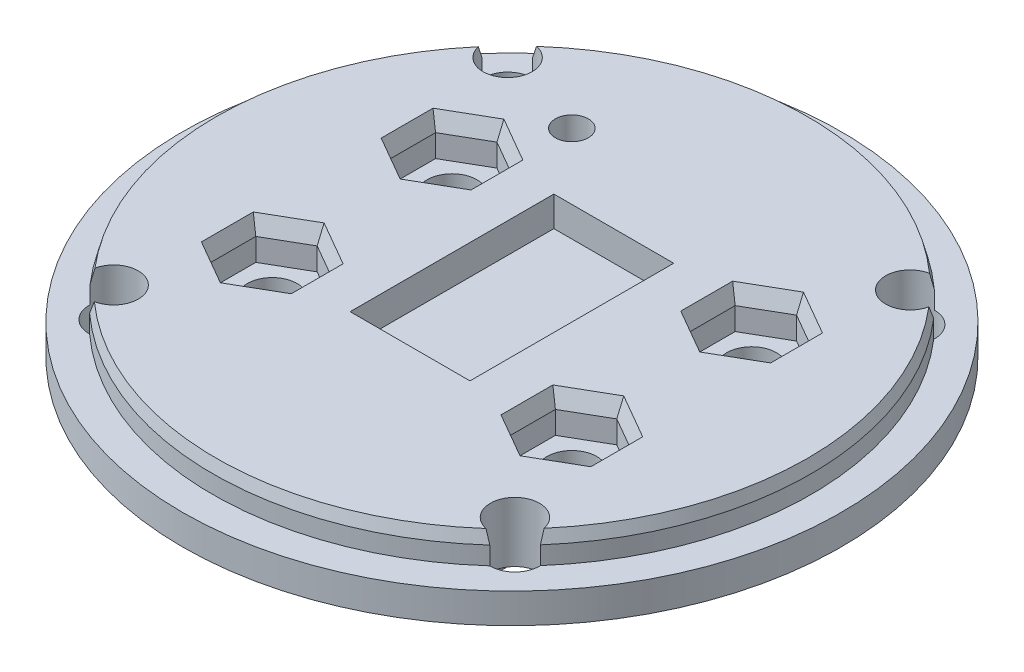
from build123d import *

# Parameters (mm, degrees)
SKETCH_1_R            = 55
EXTRUDE_1_DEPTH       = 5
SKETCH_2_R            = 49.9
EXTRUDE_2_DEPTH       = 5
SKETCH_3_W            = 35
SKETCH_3_H            = 45
EXTRUDE_3_DEPTH       = 25
SKETCH_4_W            = 20.2
SKETCH_4_H            = 10.3
CUT_EXTRUDE_1_DEPTH   = 78.5
SKETCH_5_R            = 4.1
CUT_EXTRUDE_2_DEPTH   = 11
SKETCH_6_R            = 2.75
CUT_EXTRUDE_3_DEPTH   = 36
CHAMFER1_SIZE         = 2
CHAMFER1_SIZE2        = 0.535898385
CHAMFER1_PART_2_SIZE  = 2
CHAMFER1_PART_2_SIZE2 = 0.535898385
CHAMFER1_PART_3_SIZE  = 2
CHAMFER1_PART_3_SIZE2 = 0.535898385
CHAMFER1_PART_4_SIZE  = 2
CHAMFER1_PART_4_SIZE2 = 0.535898385
SKETCH2_W             = 35.065209797
SKETCH2_H             = 45
CUT_EXTRUDE1_DEPTH    = 12.5
BOSS_EXTRUDE1_START   = -2
SKETCH4_W             = 70
SKETCH4_H             = 45
BOSS_EXTRUDE1_DEPTH   = 5.35
SKETCH5_R             = 4.15
CUT_EXTRUDE2_DEPTH    = 16.3500001
CUT_EXTRUDE3_DEPTH    = 6.5
SKETCH7_W             = 20
SKETCH7_H             = 34
CUT_EXTRUDE4_DEPTH    = 5
CHAMFER2_SIZE         = 1
CHAMFER2_SIZE2        = 2.747477419


with BuildPart() as part:
    # Эскиз1 → Бобышка-Вытянуть1 (new body)
    with BuildSketch(Plane(origin=(0, 0, 0), x_dir=(1, 0, 0), z_dir=(0, 1, 0))):
        Circle(SKETCH_1_R)
    extrude(amount=EXTRUDE_1_DEPTH)

    # Эскиз2 → Бобышка-Вытянуть2 (add)
    with BuildSketch(Plane(origin=(0, 5, 0), x_dir=(1, 0, 0), z_dir=(0, 1, 0))):
        Circle(SKETCH_2_R)
    extrude(amount=EXTRUDE_2_DEPTH)

    # Эскиз3 → Бобышка-Вытянуть3 (add)
    with BuildSketch(Plane.XZ):
        Rectangle(SKETCH_3_W, SKETCH_3_H)
    extrude(amount=EXTRUDE_3_DEPTH)

    # Эскиз4 → Вырез-Вытянуть1 (cut, through all)
    with BuildSketch(Plane.XY.offset(22.5)):
        with Locations((0, -12.5)):
            Rectangle(SKETCH_4_W, SKETCH_4_H)
    extrude(amount=-CUT_EXTRUDE_1_DEPTH, mode=Mode.SUBTRACT)

    # Эскиз5 → Вырез-Вытянуть2 (cut, through all)
    with BuildSketch(Plane.XZ):
        with Locations((33.592198598, -32.871936263)):
            Circle(SKETCH_5_R)
        with Locations((-33.591727056, -32.872418125)):
            Circle(SKETCH_5_R)
        with Locations((-33.591727056, 32.872418125)):
            Circle(SKETCH_5_R)
        with Locations((33.483215177, 32.983215177)):
            Circle(SKETCH_5_R)
    extrude(amount=-CUT_EXTRUDE_2_DEPTH, mode=Mode.SUBTRACT)

    # Эскиз6 → Вырез-Вытянуть3 (cut, through all)
    with BuildSketch(Plane(origin=(0, 10, 0), x_dir=(1, 0, 0), z_dir=(0, 1, 0))):
        with Locations((-17.999799176, 27.999999999)):
            Circle(SKETCH_6_R)
    extrude(amount=-CUT_EXTRUDE_3_DEPTH, mode=Mode.SUBTRACT)

    # Chamfer1
    chamfer1_edges = [part.edges().sort_by_distance(p)[0] for p in [
        (0.000357897, 10, -49.899999999),
    ]]
    chamfer1_side = [part.faces().sort_by_distance(p)[0] for p in [
        (0.000357897, 7.5, -49.899999999),
    ]]
    chamfer(chamfer1_edges, length=CHAMFER1_SIZE, length2=CHAMFER1_SIZE2, reference=chamfer1_side[0])

    # Chamfer1 part 2
    chamfer1_part_2_edges = [part.edges().sort_by_distance(p)[0] for p in [
        (-49.9, 10, 0),
    ]]
    chamfer1_part_2_side = [part.faces().sort_by_distance(p)[0] for p in [
        (-49.9, 7.5, 0),
    ]]
    chamfer(chamfer1_part_2_edges, length=CHAMFER1_PART_2_SIZE, length2=CHAMFER1_PART_2_SIZE2, reference=chamfer1_part_2_side[0])

    # Chamfer1 part 3
    chamfer1_part_3_edges = [part.edges().sort_by_distance(p)[0] for p in [
        (-0.08242255, 10, 49.899931929),
    ]]
    chamfer1_part_3_side = [part.faces().sort_by_distance(p)[0] for p in [
        (-0.08242255, 7.5, 49.899931929),
    ]]
    chamfer(chamfer1_part_3_edges, length=CHAMFER1_PART_3_SIZE, length2=CHAMFER1_PART_3_SIZE2, reference=chamfer1_part_3_side[0])

    # Chamfer1 part 4
    chamfer1_part_4_edges = [part.edges().sort_by_distance(p)[0] for p in [
        (49.899931657, 10, 0.082587101),
    ]]
    chamfer1_part_4_side = [part.faces().sort_by_distance(p)[0] for p in [
        (49.899931657, 7.5, 0.082587101),
    ]]
    chamfer(chamfer1_part_4_edges, length=CHAMFER1_PART_4_SIZE, length2=CHAMFER1_PART_4_SIZE2, reference=chamfer1_part_4_side[0])

    # Sketch2 → Cut-Extrude1 (cut)
    with BuildSketch(Plane.XZ.offset(25)):
        with Locations((-0.032604899, 0)):
            Rectangle(SKETCH2_W, SKETCH2_H)
    extrude(amount=-CUT_EXTRUDE1_DEPTH, mode=Mode.SUBTRACT)

    # Sketch4 → Boss-Extrude1 (add)
    with BuildSketch(Plane.XZ.offset(7.35).offset(BOSS_EXTRUDE1_START)):
        Rectangle(SKETCH4_W, SKETCH4_H)
    extrude(amount=-BOSS_EXTRUDE1_DEPTH)

    # Sketch5 → Cut-Extrude2 (cut, through all)
    with BuildSketch(Plane.XZ.offset(5.35)):
        with Locations((25, 15)):
            Circle(SKETCH5_R)
        with Locations((-25, 15)):
            Circle(SKETCH5_R)
        with Locations((25, -15)):
            Circle(SKETCH5_R)
        with Locations((-25, -15)):
            Circle(SKETCH5_R)
    extrude(amount=-CUT_EXTRUDE2_DEPTH, mode=Mode.SUBTRACT)

    # Sketch6 → Cut-Extrude3 (cut)
    with BuildSketch(Plane(origin=(0, 10, 0), x_dir=(1, 0, 0), z_dir=(0, 1, 0))):
        Polygon((-18.504809472, -11.25), (-25, -7.5), (-31.495190528, -11.25), (-31.495190528, -18.75), (-25, -22.5), (-18.504809472, -18.75), align=None)
        Polygon((31.495190528, -11.25), (25, -7.5), (18.504809472, -11.25), (18.504809472, -18.75), (25, -22.5), (31.495190528, -18.75), align=None)
        Polygon((31.495190528, 18.75), (25, 22.5), (18.504809472, 18.75), (18.504809472, 11.25), (25, 7.5), (31.495190528, 11.25), align=None)
        Polygon((-18.504809472, 18.75), (-25, 22.5), (-31.495190528, 18.75), (-31.495190528, 11.25), (-25, 7.5), (-18.504809472, 11.25), align=None)
    extrude(amount=-CUT_EXTRUDE3_DEPTH, mode=Mode.SUBTRACT)

    # Sketch7 → Cut-Extrude4 (cut)
    with BuildSketch(Plane(origin=(0, 10, 0), x_dir=(1, 0, 0), z_dir=(0, 1, 0))):
        Rectangle(SKETCH7_W, SKETCH7_H)
    extrude(amount=-CUT_EXTRUDE4_DEPTH, mode=Mode.SUBTRACT)

    # Chamfer2
    chamfer2_edges = [part.edges().sort_by_distance(p)[0] for p in [
        (-18.504809472, 10, 15),
        (-21.752404736, 10, 9.375),
        (-28.247595264, 10, 9.375),
        (-31.495190528, 10, 15),
        (-28.247595264, 10, 20.625),
        (-21.752404736, 10, 20.625),
        (31.495190528, 10, 15),
        (28.247595264, 10, 9.375),
        (21.752404736, 10, 9.375),
        (18.504809472, 10, 15),
        (21.752404736, 10, 20.625),
        (28.247595264, 10, 20.625),
        (31.495190528, 10, -15),
        (28.247595264, 10, -20.625),
        (21.752404736, 10, -20.625),
        (18.504809472, 10, -15),
        (21.752404736, 10, -9.375),
        (28.247595264, 10, -9.375),
        (-18.504809472, 10, -15),
        (-21.752404736, 10, -20.625),
        (-28.247595264, 10, -20.625),
        (-31.495190528, 10, -15),
        (-28.247595264, 10, -9.375),
        (-21.752404736, 10, -9.375),
    ]]
    chamfer2_side = [part.faces().sort_by_distance(p)[0] for p in [
        (29.567670169, 10, 29.126140435),
    ]]
    chamfer(chamfer2_edges, length=CHAMFER2_SIZE, length2=CHAMFER2_SIZE2, reference=chamfer2_side[0])


solid = part.part
